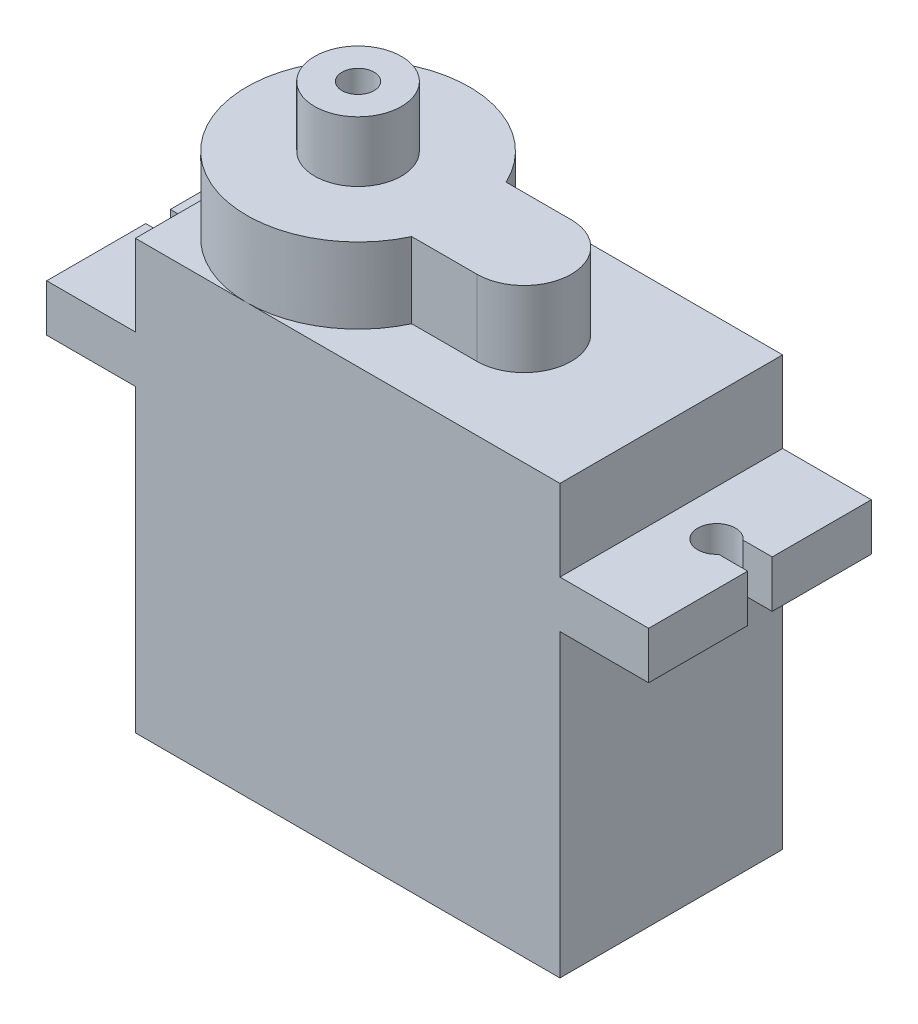
from build123d import *

# Parameters (mm, degrees)
SKETCH2_W           = 22.5
SKETCH2_H           = 22.7
BOSS_EXTRUDE1_DEPTH = 5.9
BOSS_EXTRUDE2_DEPTH = 2.5
BOSS_EXTRUDE3_DEPTH = 4
SKETCH5_R           = 2.3
SKETCH5_R_2         = 0.85
BOSS_EXTRUDE4_DEPTH = 3.2


with BuildPart() as part:
    # Sketch2 → Boss-Extrude1 (new body, symmetric)
    with BuildSketch(Plane.XY):
        Rectangle(SKETCH2_W, SKETCH2_H)
    extrude(amount=BOSS_EXTRUDE1_DEPTH, both=True)

    # Sketch3 → Boss-Extrude2 (add)
    with BuildSketch(Plane(origin=(0, 4.55, 0), x_dir=(-1, 0, 0), z_dir=(0, -1, 0))):
        with BuildLine():
            Line((14.409934208, 0.65), (15.95, 0.65))
            Line((15.95, 0.65), (15.95, 5.9))
            Line((15.95, 5.9), (11.25, 5.9))
            Line((11.25, 5.9), (11.25, -5.9))
            Line((11.25, -5.9), (15.95, -5.9))
            Line((15.95, -5.9), (15.95, -0.65))
            Line((15.95, -0.65), (14.409934208, -0.65))
            ThreePointArc((14.409934208, -0.65), (12.65, 0), (14.409934208, 0.65))
        make_face()
        with BuildLine():
            Line((-11.25, -5.9), (-15.95, -5.9))
            Line((-15.95, -5.9), (-15.95, -0.65))
            Line((-15.95, -0.65), (-14.409934208, -0.65))
            ThreePointArc((-14.409934208, -0.65), (-12.65, 0), (-14.409934208, 0.65))
            Line((-14.409934208, 0.65), (-15.95, 0.65))
            Line((-15.95, 0.65), (-15.95, 5.9))
            Line((-15.95, 5.9), (-11.25, 5.9))
            Line((-11.25, 5.9), (-11.25, -5.9))
        make_face()
    extrude(amount=-BOSS_EXTRUDE2_DEPTH)

    # Sketch4 → Boss-Extrude3 (add)
    with BuildSketch(Plane(origin=(0, 11.35, 0), x_dir=(1, 0, 0), z_dir=(0, 1, 0))):
        with BuildLine():
            Line((3.45, 2.5), (-0.005844314, 2.5))
            ThreePointArc((-0.005844314, 2.5), (-11.25, 0), (-0.005844314, -2.5))
            Line((-0.005844314, -2.5), (3.45, -2.5))
            ThreePointArc((3.45, -2.5), (5.95, 0), (3.45, 2.5))
        make_face()
    extrude(amount=BOSS_EXTRUDE3_DEPTH)

    # Sketch5 → Boss-Extrude4 (add)
    with BuildSketch(Plane(origin=(0, 15.35, 0), x_dir=(1, 0, 0), z_dir=(0, 1, 0))):
        with Locations((-5.35, 0)):
            Circle(SKETCH5_R)
        with Locations((-5.35, 0)):
            Circle(SKETCH5_R_2, mode=Mode.SUBTRACT)
    extrude(amount=BOSS_EXTRUDE4_DEPTH)


solid = part.part
